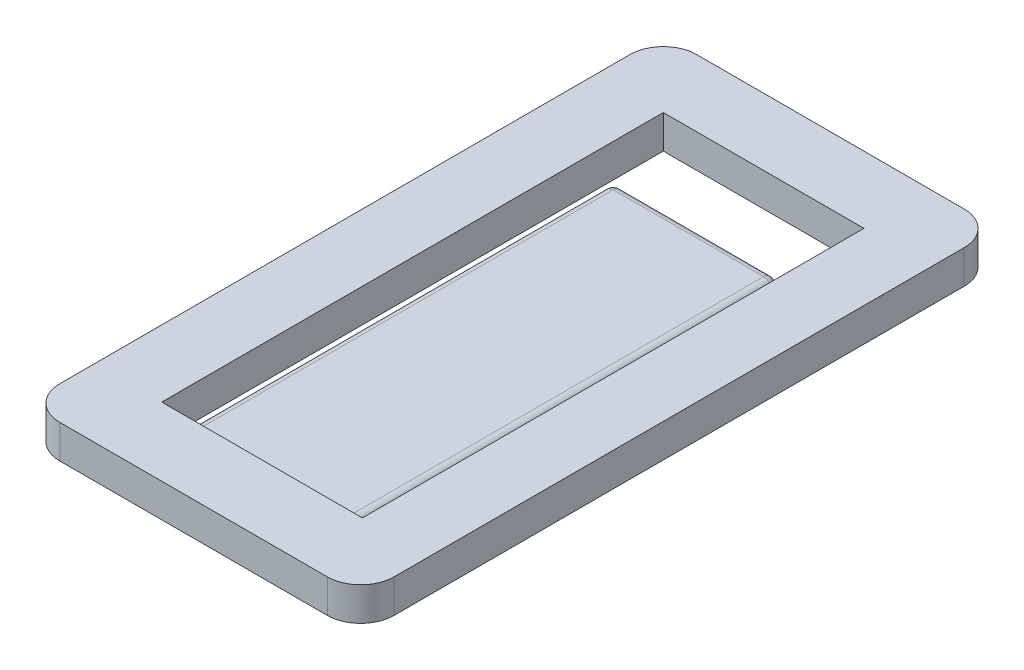
from build123d import *

# Parameters (mm, degrees)
SKETCH1_W               = 10
SKETCH1_H               = 19.05
BOSS_EXTRUDE1_DEPTH     = 1
SKETCH2_W               = 0.5
SKETCH2_H               = 15
CUT_EXTRUDE1_DEPTH      = 1
CUT_EXTRUDE1_DEPTH_BACK = 2
SKETCH3_W               = 0.5
SKETCH3_H               = 15
CUT_EXTRUDE2_DEPTH      = 2
SKETCH4_W               = 5
SKETCH4_H               = 2
CUT_EXTRUDE3_DEPTH      = 2
SKETCH5_W               = 5
SKETCH5_H               = 13
CUT_EXTRUDE4_DEPTH      = 0.5
FILLET9_R               = 0.25
FILLET10_R              = 0.25
FILLET11_R              = 0.25
FILLET13_R              = 1
FILLET14_R              = 1
FILLET15_R              = 1
FILLET16_R              = 1


with BuildPart() as part:
    # Sketch1 → Boss-Extrude1 (new body)
    with BuildSketch(Plane(origin=(0, 0, 0), x_dir=(1, 0, 0), z_dir=(0, 1, 0))):
        Rectangle(SKETCH1_W, SKETCH1_H)
    extrude(amount=BOSS_EXTRUDE1_DEPTH)

    # Sketch2 → Cut-Extrude1 (cut, two sides)
    with BuildSketch(Plane(origin=(0, 1, 0), x_dir=(1, 0, 0), z_dir=(0, 1, 0))) as cut_extrude1_sk:
        with Locations((-2.75, 0.025)):
            Rectangle(SKETCH2_W, SKETCH2_H)
    extrude(amount=CUT_EXTRUDE1_DEPTH, mode=Mode.SUBTRACT)
    extrude(cut_extrude1_sk.sketch, amount=-CUT_EXTRUDE1_DEPTH_BACK, mode=Mode.SUBTRACT)

    # Sketch3 → Cut-Extrude2 (cut, through all)
    with BuildSketch(Plane(origin=(0, 1, 0), x_dir=(1, 0, 0), z_dir=(0, 1, 0))):
        with Locations((2.75, 0.025)):
            Rectangle(SKETCH3_W, SKETCH3_H)
    extrude(amount=-CUT_EXTRUDE2_DEPTH, mode=Mode.SUBTRACT)

    # Sketch4 → Cut-Extrude3 (cut, through all)
    with BuildSketch(Plane(origin=(0, 1, 0), x_dir=(1, 0, 0), z_dir=(0, 1, 0))):
        with Locations((0, 6.525)):
            Rectangle(SKETCH4_W, SKETCH4_H)
    extrude(amount=-CUT_EXTRUDE3_DEPTH, mode=Mode.SUBTRACT)

    # Sketch5 → Cut-Extrude4 (cut)
    with BuildSketch(Plane(origin=(0, 1, 0), x_dir=(1, 0, 0), z_dir=(0, 1, 0))):
        with Locations((0, -0.975)):
            Rectangle(SKETCH5_W, SKETCH5_H)
    extrude(amount=-CUT_EXTRUDE4_DEPTH, mode=Mode.SUBTRACT)

    # Fillet9
    fillet9_edges = [part.edges().sort_by_distance(p)[0] for p in [
        (0, 0.5, -5.525),
    ]]
    fillet(fillet9_edges, radius=FILLET9_R)

    # Fillet10
    fillet10_edges = [part.edges().sort_by_distance(p)[0] for p in [
        (-2.5, 0.125, -5.525),
        (-2.5, 0.5, 1.1),
    ]]
    fillet(fillet10_edges, radius=FILLET10_R)

    # Fillet11
    fillet11_edges = [part.edges().sort_by_distance(p)[0] for p in [
        (2.5, 0.125, -5.525),
        (2.5, 0.5, 1.1),
    ]]
    fillet(fillet11_edges, radius=FILLET11_R)

    # Fillet13
    fillet13_edges = [part.edges().sort_by_distance(p)[0] for p in [
        (-5, 0.5, -9.525),
    ]]
    fillet(fillet13_edges, radius=FILLET13_R)

    # Fillet14
    fillet14_edges = [part.edges().sort_by_distance(p)[0] for p in [
        (5, 0.5, -9.525),
    ]]
    fillet(fillet14_edges, radius=FILLET14_R)

    # Fillet15
    fillet15_edges = [part.edges().sort_by_distance(p)[0] for p in [
        (5, 0.5, 9.525),
    ]]
    fillet(fillet15_edges, radius=FILLET15_R)

    # Fillet16
    fillet16_edges = [part.edges().sort_by_distance(p)[0] for p in [
        (-5, 0.5, 9.525),
    ]]
    fillet(fillet16_edges, radius=FILLET16_R)


solid = part.part
